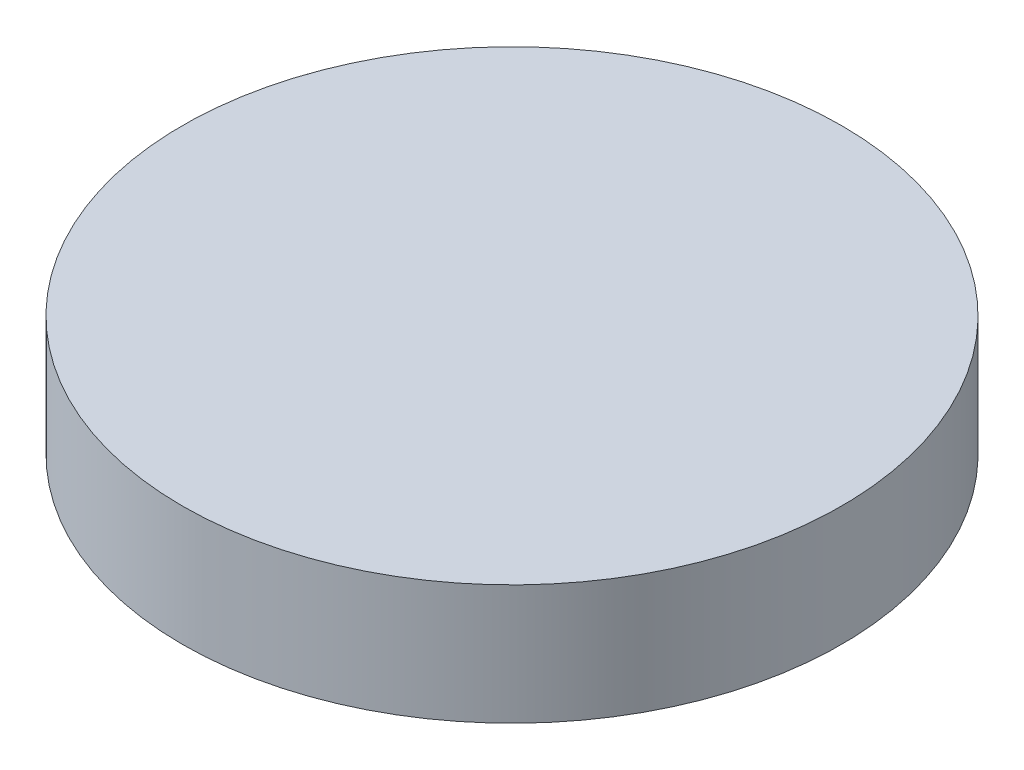
from build123d import *

# Parameters (mm, degrees)
SKETCH_1_R      = 8.25
EXTRUDE_1_DEPTH = 3


with BuildPart() as part:
    # 草图1 → 凸台-拉伸1 (new body)
    with BuildSketch(Plane(origin=(0, 0, 0), x_dir=(1, 0, 0), z_dir=(0, 1, 0))):
        Circle(SKETCH_1_R)
    extrude(amount=EXTRUDE_1_DEPTH)


solid = part.part
